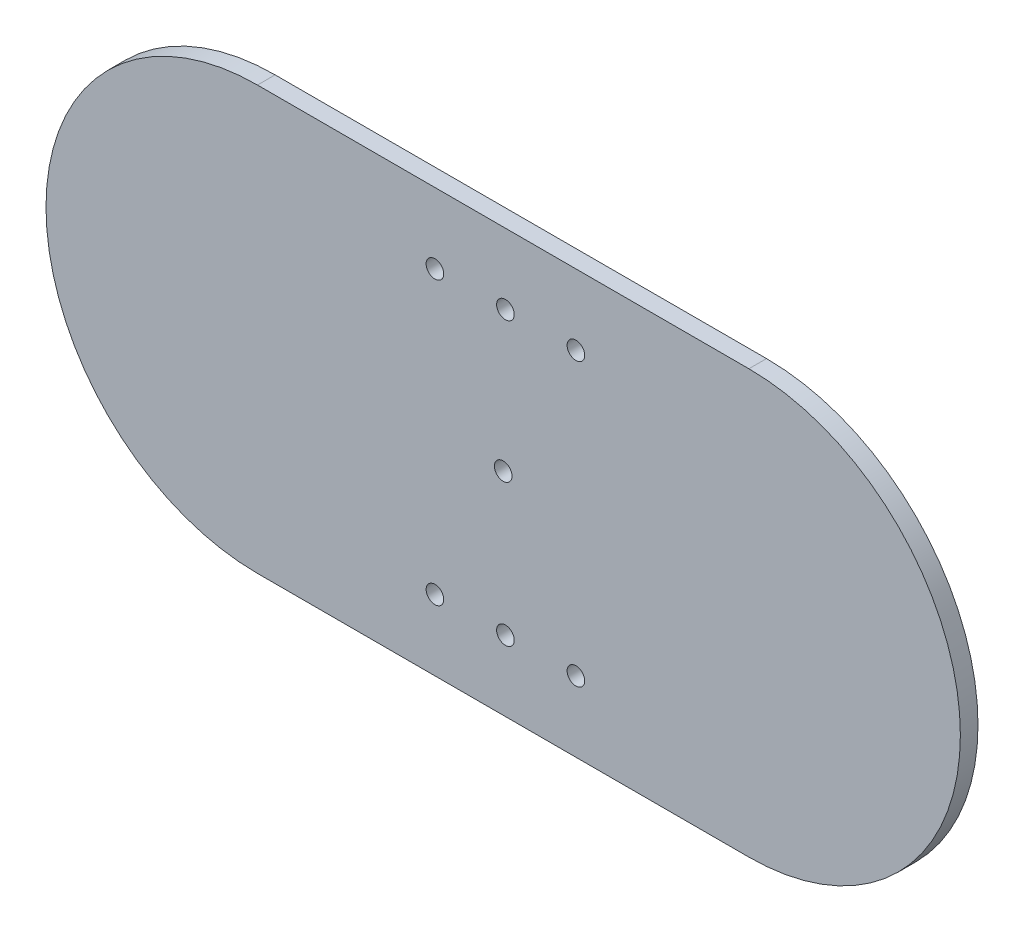
from build123d import *

# Parameters (mm, degrees)
SKETCH1_R           = 3.175
BOSS_EXTRUDE1_DEPTH = 6.35


with BuildPart() as part:
    # Sketch1 → Boss-Extrude1 (new body)
    with BuildSketch(Plane.XY):
        with BuildLine():
            Line((-81.15451448, 76.2), (95.90988075, 76.2))
            ThreePointArc((95.90988075, 76.2), (172.10988075, 0), (95.90988075, -76.2))
            Line((95.90988075, -76.2), (-81.15451448, -76.2))
            ThreePointArc((-81.15451448, -76.2), (-157.35451448, 0), (-81.15451448, 76.2))
        make_face()
        with Locations((8.184238886, 50.8)):
            Circle(SKETCH1_R, mode=Mode.SUBTRACT)
        with Locations((8.184238886, -50.8)):
            Circle(SKETCH1_R, mode=Mode.SUBTRACT)
        with Locations((-17.215761114, 50.8)):
            Circle(SKETCH1_R, mode=Mode.SUBTRACT)
        with Locations((33.584238886, 50.8)):
            Circle(SKETCH1_R, mode=Mode.SUBTRACT)
        with Locations((33.584238886, -50.8)):
            Circle(SKETCH1_R, mode=Mode.SUBTRACT)
        with Locations((-17.215761114, -50.8)):
            Circle(SKETCH1_R, mode=Mode.SUBTRACT)
        with Locations((7.377683135, 0)):
            Circle(SKETCH1_R, mode=Mode.SUBTRACT)
    extrude(amount=BOSS_EXTRUDE1_DEPTH)


solid = part.part
